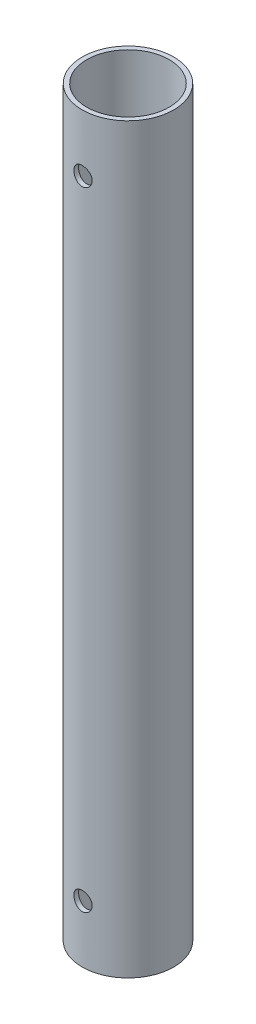
from build123d import *

# Parameters (mm, degrees)
SKETCH1_R           = 10
SKETCH1_R_2         = 9
BOSS_EXTRUDE1_DEPTH = 162
SKETCH3_R           = 2
CUT_EXTRUDE2_DEPTH  = 21


with BuildPart() as part:
    # Sketch1 → Boss-Extrude1 (new body)
    with BuildSketch(Plane(origin=(0, 0, 0), x_dir=(1, 0, 0), z_dir=(0, 1, 0))):
        Circle(SKETCH1_R)
        Circle(SKETCH1_R_2, mode=Mode.SUBTRACT)
    extrude(amount=BOSS_EXTRUDE1_DEPTH)

    # Sketch3 → Cut-Extrude2 (cut, through all)
    with BuildSketch(Plane.XY.offset(10)):
        with Locations((0, 149.5)):
            Circle(SKETCH3_R)
        with Locations((0, 12.5)):
            Circle(SKETCH3_R)
    extrude(amount=-CUT_EXTRUDE2_DEPTH, mode=Mode.SUBTRACT)


solid = part.part
